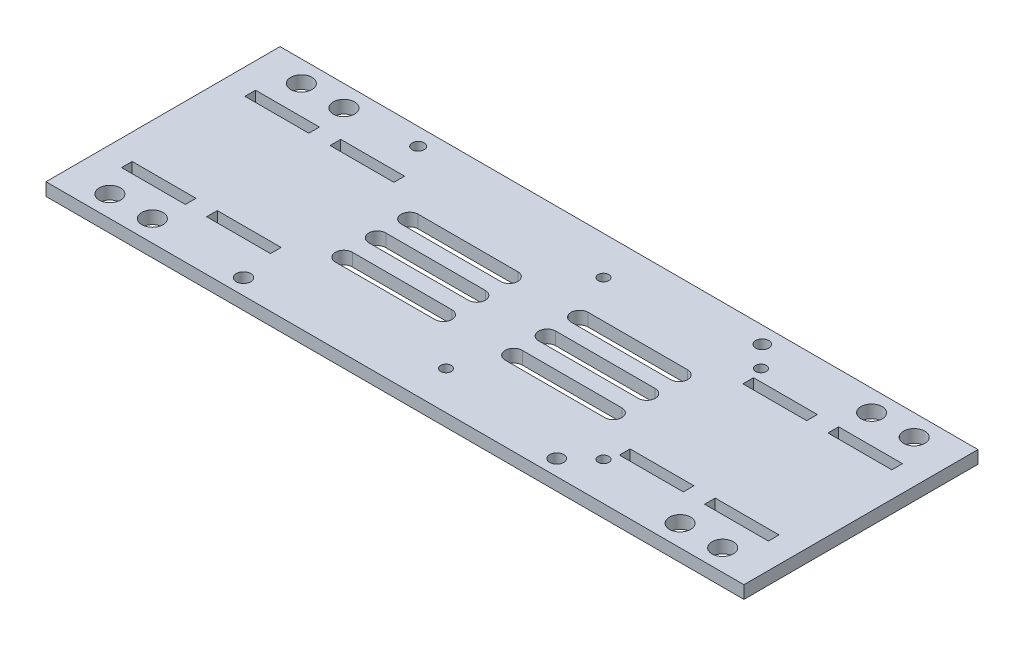
from build123d import *

# Parameters (mm, degrees)
SKETCH1_W           = 164
SKETCH1_H           = 55
SKETCH1_W_2         = 15
SKETCH1_H_2         = 2.5
BOSS_EXTRUDE1_DEPTH = 3
CUT_EXTRUDE1_DEPTH  = 3
SKETCH3_R           = 1.25
CUT_EXTRUDE2_DEPTH  = 10
SKETCH4_R           = 2.5
CUT_EXTRUDE3_DEPTH  = 4
SKETCH5_R           = 1.63582752
SKETCH5_R_2         = 1.550817753
SKETCH5_R_3         = 1.410083192
SKETCH5_R_4         = 1.692495787
CUT_EXTRUDE4_DEPTH  = 4


with BuildPart() as part:
    # Sketch1 → Boss-Extrude1 (new body)
    with BuildSketch(Plane(origin=(0, 0, 0), x_dir=(1, 0, 0), z_dir=(0, 1, 0))):
        Rectangle(SKETCH1_W, SKETCH1_H)
        with Locations((48.5, 14.5)):
            Rectangle(SKETCH1_W_2, SKETCH1_H_2, mode=Mode.SUBTRACT)
        with Locations((68.5, 14.5)):
            Rectangle(SKETCH1_W_2, SKETCH1_H_2, mode=Mode.SUBTRACT)
        with Locations((68.5, -14.5)):
            Rectangle(SKETCH1_W_2, SKETCH1_H_2, mode=Mode.SUBTRACT)
        with Locations((48.5, -14.5)):
            Rectangle(SKETCH1_W_2, SKETCH1_H_2, mode=Mode.SUBTRACT)
        with Locations((-48.5, -14.5)):
            Rectangle(SKETCH1_W_2, SKETCH1_H_2, mode=Mode.SUBTRACT)
        with Locations((-68.5, -14.5)):
            Rectangle(SKETCH1_W_2, SKETCH1_H_2, mode=Mode.SUBTRACT)
        with Locations((-68.5, 14.5)):
            Rectangle(SKETCH1_W_2, SKETCH1_H_2, mode=Mode.SUBTRACT)
        with Locations((-48.5, 14.5)):
            Rectangle(SKETCH1_W_2, SKETCH1_H_2, mode=Mode.SUBTRACT)
    extrude(amount=BOSS_EXTRUDE1_DEPTH)

    # Sketch2 → Cut-Extrude1 (cut)
    with BuildSketch(Plane(origin=(0, 3, 0), x_dir=(1, 0, 0), z_dir=(0, 1, 0))):
        with BuildLine():
            Line((-31.658505885, 2), (-8.266387648, 2))
            ThreePointArc((-8.266387648, 2), (-6.266387648, 0), (-8.266387648, -2))
            Line((-8.266387648, -2), (-31.658505885, -2))
            ThreePointArc((-31.658505885, -2), (-33.658505885, 0), (-31.658505885, 2))
        make_face()
        with BuildLine():
            Line((31.658505885, -9.856733432), (8.266387648, -9.856733432))
            ThreePointArc((8.266387648, -9.856733432), (6.266387648, -7.856733432), (8.266387648, -5.856733432))
            Line((8.266387648, -5.856733432), (31.658505885, -5.856733432))
            ThreePointArc((31.658505885, -5.856733432), (33.658505885, -7.856733432), (31.658505885, -9.856733432))
        make_face()
        with BuildLine():
            Line((-31.658505885, 9.620758334), (-8.266387648, 9.620758334))
            ThreePointArc((-8.266387648, 9.620758334), (-6.266387648, 7.620758334), (-8.266387648, 5.620758334))
            Line((-8.266387648, 5.620758334), (-31.658505885, 5.620758334))
            ThreePointArc((-31.658505885, 5.620758334), (-33.658505885, 7.620758334), (-31.658505885, 9.620758334))
        make_face()
        with BuildLine():
            Line((31.658505885, 5.620758334), (8.266387648, 5.620758334))
            ThreePointArc((8.266387648, 5.620758334), (6.266387648, 7.620758334), (8.266387648, 9.620758334))
            Line((8.266387648, 9.620758334), (31.658505885, 9.620758334))
            ThreePointArc((31.658505885, 9.620758334), (33.658505885, 7.620758334), (31.658505885, 5.620758334))
        make_face()
        with BuildLine():
            Line((-31.658505885, -5.856733432), (-8.266387648, -5.856733432))
            ThreePointArc((-8.266387648, -5.856733432), (-6.266387648, -7.856733432), (-8.266387648, -9.856733432))
            Line((-8.266387648, -9.856733432), (-31.658505885, -9.856733432))
            ThreePointArc((-31.658505885, -9.856733432), (-33.658505885, -7.856733432), (-31.658505885, -5.856733432))
        make_face()
        with BuildLine():
            Line((31.658505885, -2), (8.266387648, -2))
            ThreePointArc((8.266387648, -2), (6.266387648, 0), (8.266387648, 2))
            Line((8.266387648, 2), (31.658505885, 2))
            ThreePointArc((31.658505885, 2), (33.658505885, 0), (31.658505885, -2))
        make_face()
    extrude(amount=-CUT_EXTRUDE1_DEPTH, mode=Mode.SUBTRACT)

    # Sketch3 → Cut-Extrude2 (cut)
    with BuildSketch(Plane(origin=(0, 3, 0), x_dir=(1, 0, 0), z_dir=(0, 1, 0))):
        with Locations((40, 18.5)):
            Circle(SKETCH3_R)
        with Locations((40, -18.5)):
            Circle(SKETCH3_R)
        with Locations((3, -18.5)):
            Circle(SKETCH3_R)
        with Locations((3, 18.5)):
            Circle(SKETCH3_R)
    extrude(amount=-CUT_EXTRUDE2_DEPTH, mode=Mode.SUBTRACT)

    # Sketch4 → Cut-Extrude3 (cut, through all)
    with BuildSketch(Plane(origin=(0, 3, 0), x_dir=(1, 0, 0), z_dir=(0, 1, 0))):
        with Locations((72, -22.5)):
            Circle(SKETCH4_R)
        with Locations((62, -22.5)):
            Circle(SKETCH4_R)
        with Locations((72, 22.5)):
            Circle(SKETCH4_R)
        with Locations((62, 22.5)):
            Circle(SKETCH4_R)
        with Locations((-72, 22.5)):
            Circle(SKETCH4_R)
        with Locations((-62, 22.5)):
            Circle(SKETCH4_R)
        with Locations((-72, -22.5)):
            Circle(SKETCH4_R)
        with Locations((-62, -22.5)):
            Circle(SKETCH4_R)
    extrude(amount=-CUT_EXTRUDE3_DEPTH, mode=Mode.SUBTRACT)

    # Sketch5 → Cut-Extrude4 (cut, through all)
    with BuildSketch(Plane(origin=(0, 3, 0), x_dir=(1, 0, 0), z_dir=(0, 1, 0))):
        with Locations((34.323103301, -23.81549711)):
            Circle(SKETCH5_R)
        with Locations((35.235754497, 23.565498985)):
            Circle(SKETCH5_R_2)
        with Locations((-45.484369153, 23.437784188)):
            Circle(SKETCH5_R_3)
        with Locations((-39.276258797, -23.81549711)):
            Circle(SKETCH5_R_4)
    extrude(amount=-CUT_EXTRUDE4_DEPTH, mode=Mode.SUBTRACT)


solid = part.part
